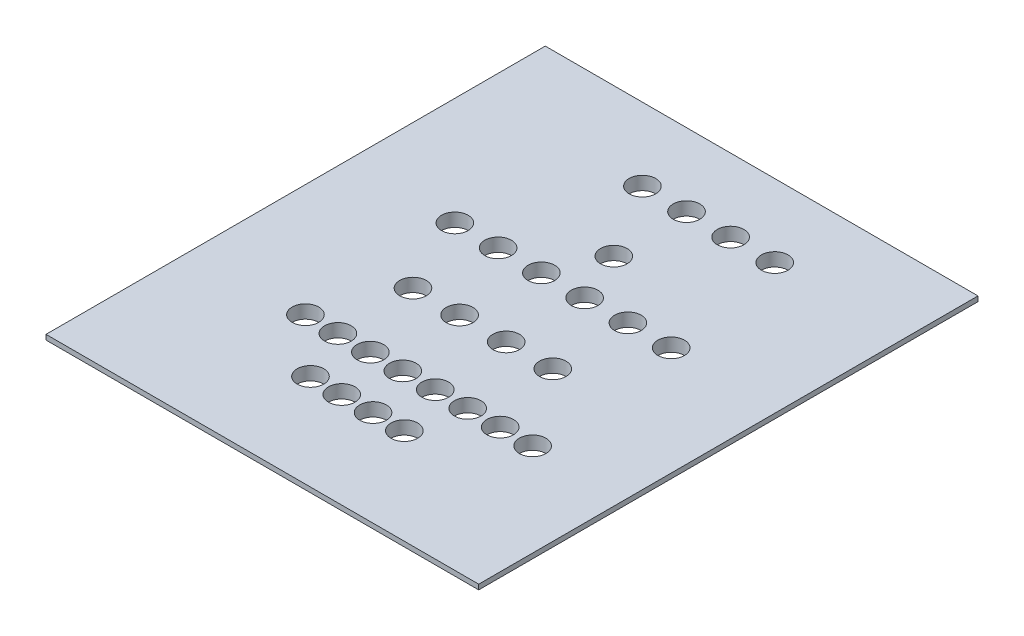
from build123d import *

# Parameters (mm, degrees)
SKETCH_1_W          = 260
SKETCH_1_H          = 300
EXTRUDE_1_DEPTH     = 10
SKETCH_2_W          = 220
SKETCH_2_H          = 260
CUT_EXTRUDE_1_DEPTH = 2
M3X0_51_D           = 2.5
M3X0_51_DEPTH       = 8.5
M3X0_51_TIP         = 0.751075774
SKETCH_9_W          = 260
SKETCH_9_H          = 300
SKETCH_9_W_2        = 240
SKETCH_9_H_2        = 280
CUT_EXTRUDE_3_DEPTH = 7
SKETCH_10_R         = 8
CUT_EXTRUDE_4_DEPTH = 11


with BuildPart() as part:
    # Эскиз1 → Бобышка-Вытянуть1 (new body)
    with BuildSketch(Plane(origin=(0, 0, 0), x_dir=(1, 0, 0), z_dir=(0, 1, 0))):
        Rectangle(SKETCH_1_W, SKETCH_1_H)
    extrude(amount=EXTRUDE_1_DEPTH)

    # Эскиз2 → Вырез-Вытянуть1 (cut)
    with BuildSketch(Plane.XZ):
        Rectangle(SKETCH_2_W, SKETCH_2_H)
    extrude(amount=-CUT_EXTRUDE_1_DEPTH, mode=Mode.SUBTRACT)

    # Отверстие обработанное метчиком M3x0.51
    with Locations(Plane(origin=(0, 0, 0), x_dir=(-1, 0, 0), z_dir=(0, -1, 0))):
        with Locations((-115, 135), (0, 135), (115, 135), (115, -135), (0, -135), (-115, -135), (115, 0), (-115, 0)):
            Hole(M3X0_51_D / 2, depth=M3X0_51_DEPTH)
            with Locations((0, 0, -(M3X0_51_DEPTH + M3X0_51_TIP / 2))):  # 118° drill point
                Cone(0, M3X0_51_D / 2, M3X0_51_TIP, mode=Mode.SUBTRACT)

    # Эскиз9 → Вырез-Вытянуть3 (cut)
    with BuildSketch(Plane.XZ):
        Rectangle(SKETCH_9_W, SKETCH_9_H)
        Rectangle(SKETCH_9_W_2, SKETCH_9_H_2, mode=Mode.SUBTRACT)
    extrude(amount=-CUT_EXTRUDE_3_DEPTH, mode=Mode.SUBTRACT)

    # Эскиз10 → Вырез-Вытянуть4 (cut, through all)
    with BuildSketch(Plane(origin=(0, 10, 0), x_dir=(1, 0, 0), z_dir=(0, 1, 0))):
        with Locations((74.221236429, -61.829520648)):
            Circle(SKETCH_10_R)
        with Locations((54.721236429, -61.829520648)):
            Circle(SKETCH_10_R)
        with Locations((35.221236429, -61.829520648)):
            Circle(SKETCH_10_R)
        with Locations((15.721236429, -61.829520648)):
            Circle(SKETCH_10_R)
        with Locations((-3.778763571, -61.829520648)):
            Circle(SKETCH_10_R)
        with Locations((-23.278763571, -61.829520648)):
            Circle(SKETCH_10_R)
        with Locations((-42.778763571, -61.829520648)):
            Circle(SKETCH_10_R)
        with Locations((-62.278763571, -61.829520648)):
            Circle(SKETCH_10_R)
        with Locations((27.756724611, -92.443317545)):
            Circle(SKETCH_10_R)
        with Locations((8.956724611, -92.443317545)):
            Circle(SKETCH_10_R)
        with Locations((-9.843275389, -92.443317545)):
            Circle(SKETCH_10_R)
        with Locations((-28.643275389, -92.443317545)):
            Circle(SKETCH_10_R)
        with Locations((40.197994593, -15.695954372)):
            Circle(SKETCH_10_R)
        with Locations((12.197994593, -15.695954372)):
            Circle(SKETCH_10_R)
        with Locations((-15.802005407, -15.695954372)):
            Circle(SKETCH_10_R)
        with Locations((-43.802005407, -15.695954372)):
            Circle(SKETCH_10_R)
        with Locations((64.84147229, 30.806375684)):
            Circle(SKETCH_10_R)
        with Locations((38.84147229, 30.806375684)):
            Circle(SKETCH_10_R)
        with Locations((12.84147229, 30.806375684)):
            Circle(SKETCH_10_R)
        with Locations((-13.15852771, 30.806375684)):
            Circle(SKETCH_10_R)
        with Locations((-39.15852771, 30.806375684)):
            Circle(SKETCH_10_R)
        with Locations((-65.15852771, 30.806375684)):
            Circle(SKETCH_10_R)
        with Locations((51.575799991, 106.283379385)):
            Circle(SKETCH_10_R)
        with Locations((25.075799991, 106.283379385)):
            Circle(SKETCH_10_R)
        with Locations((-1.424200009, 106.283379385)):
            Circle(SKETCH_10_R)
        with Locations((-27.924200009, 106.283379385)):
            Circle(SKETCH_10_R)
        with Locations((-0.103593652, 61.276056387)):
            Circle(SKETCH_10_R)
    extrude(amount=-CUT_EXTRUDE_4_DEPTH, mode=Mode.SUBTRACT)


solid = part.part
